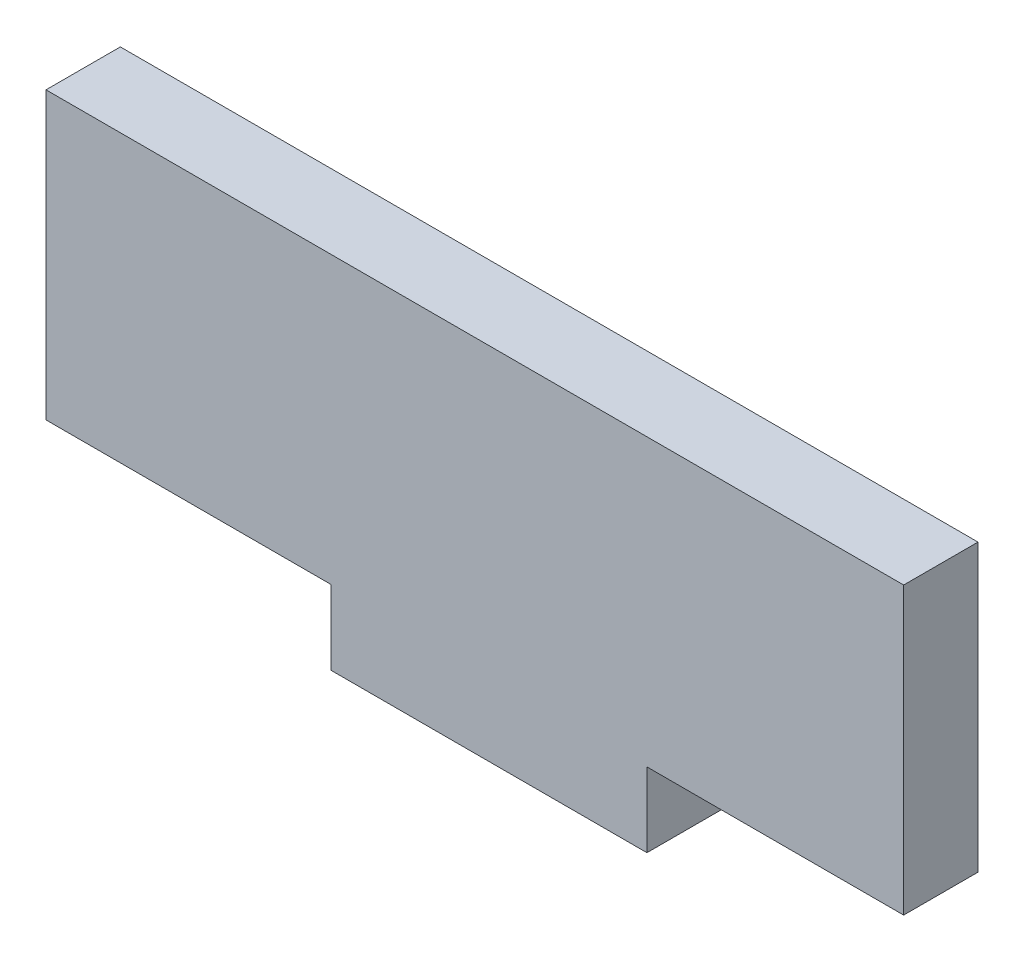
from build123d import *

# Parameters (mm, degrees)
BOSS_EXTRUDE1_DEPTH = 2.6


with BuildPart() as part:
    # Sketch1 → Boss-Extrude1 (new body)
    with BuildSketch(Plane.XY):
        Polygon((21.020160869, 0), (30, 0), (30, 10), (0, 10), (0, 0), (9.97731138, 0), (9.97731138, -2.6), (21.020160869, -2.6), align=None)
    extrude(amount=BOSS_EXTRUDE1_DEPTH)


solid = part.part
